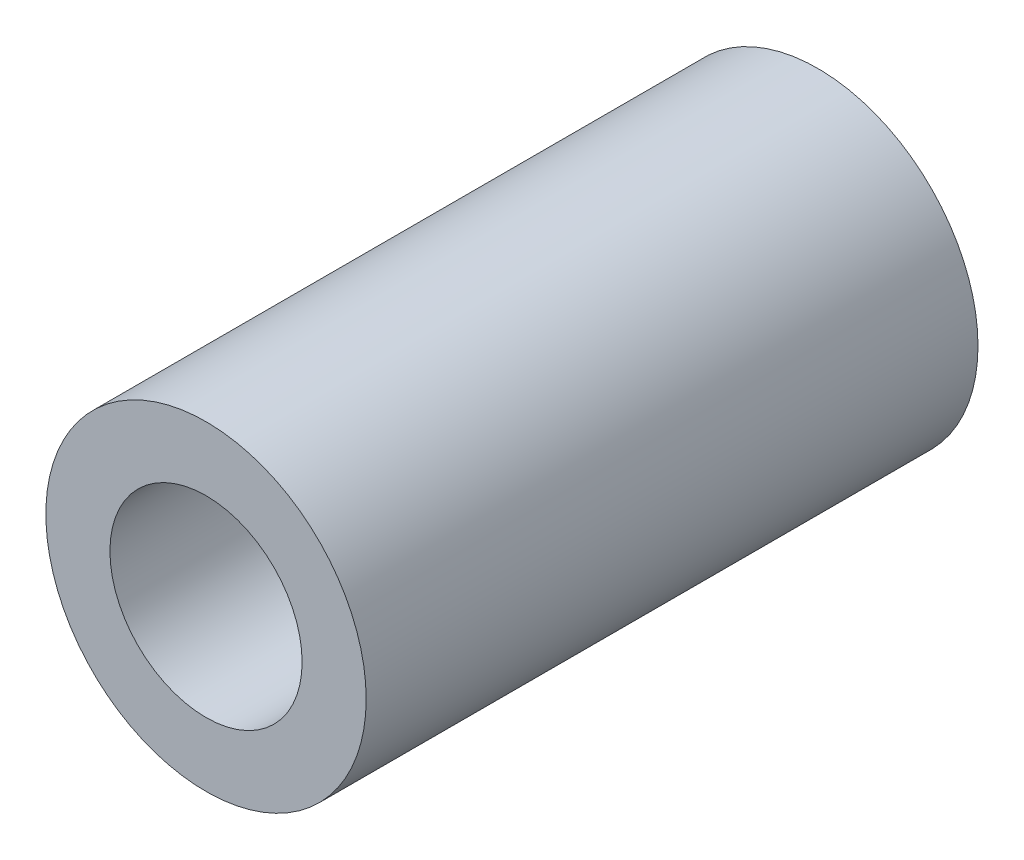
from build123d import *

# Parameters (mm, degrees)
SKETCH2_R           = 2.5
SKETCH2_R_2         = 1.5
BOSS_EXTRUDE1_DEPTH = 9.55


with BuildPart() as part:
    # Sketch2 → Boss-Extrude1 (new body)
    with BuildSketch(Plane.XY):
        Circle(SKETCH2_R)
        Circle(SKETCH2_R_2, mode=Mode.SUBTRACT)
    extrude(amount=BOSS_EXTRUDE1_DEPTH)


solid = part.part
